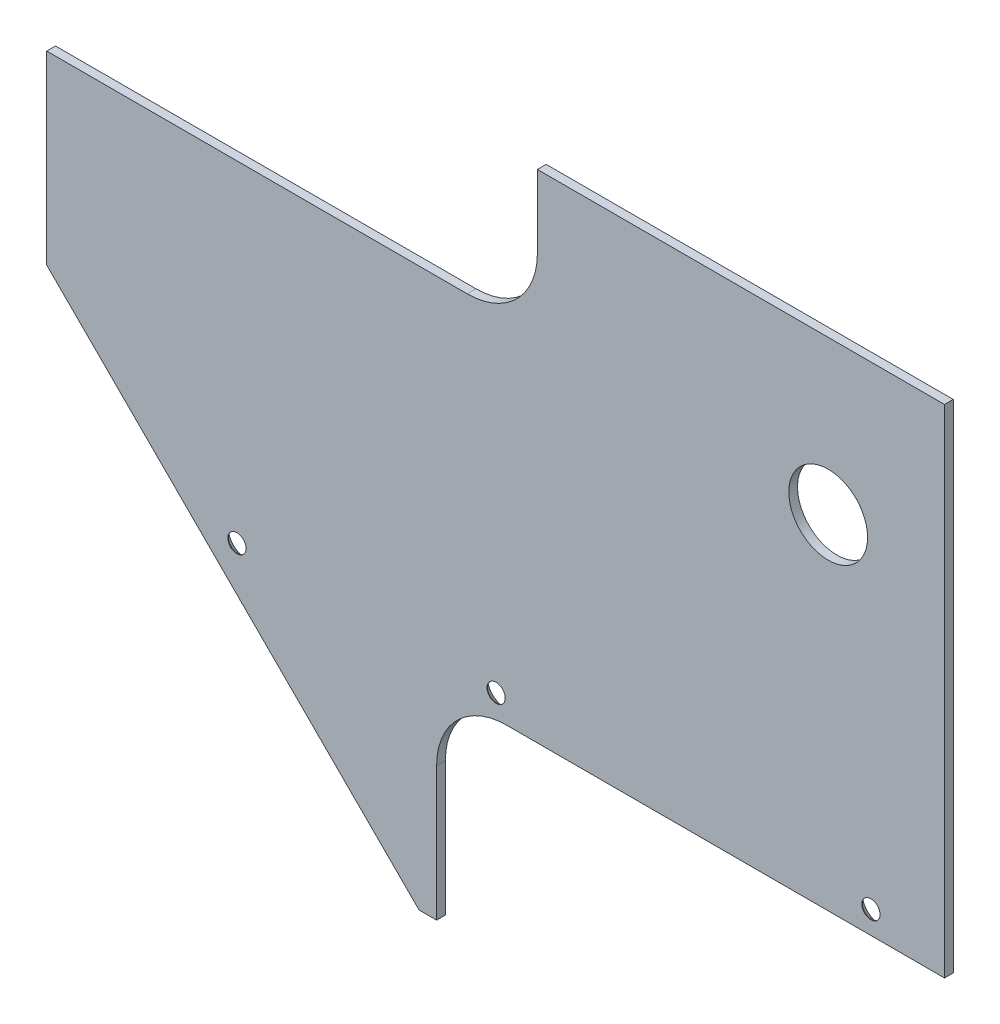
from build123d import *

# Parameters (mm, degrees)
SKETCH1_R                                      = 14.2875
BOSS_EXTRUDE1_DEPTH                            = 3.175
SKETCH2_W                                      = 184.202806358
SKETCH2_H                                      = 73.914
CUT_EXTRUDE1_DEPTH                             = 4.175
FILLET1_R                                      = 25.4
SKETCH4_W                                      = 213.36
SKETCH4_H                                      = 64.479988722
CUT_EXTRUDE2_DEPTH                             = 4.175
FILLET2_R                                      = 25.4
SKETCH7_W                                      = 147.610011278
SKETCH7_H                                      = 12.7
CUT_EXTRUDE4_DEPTH                             = 4.175
CSK_FOR_M6_FLAT_HEAD_MACHINE_SCREW1_AT_2_COUNT = 2
CSK_FOR_M6_FLAT_HEAD_MACHINE_SCREW1_AT_2_PITCH = 135.89
CSK_FOR_M6_FLAT_HEAD_MACHINE_SCREW1_AT_3_COUNT = 2
CSK_FOR_M6_FLAT_HEAD_MACHINE_SCREW1_AT_3_PITCH = 229.87
SKETCH10_W                                     = 57.863879914
SKETCH10_H                                     = 74.228534035
CUT_EXTRUDE5_DEPTH                             = 4.175


with BuildPart() as part:
    # Sketch1 → Boss-Extrude1 (new body)
    with BuildSketch(Plane.XY):
        Polygon((-138.259383474, 48.991487021), (32.210627804, -121.478524257), (222.710627804, -121.478524257), (222.710627804, 145.221475743), (-138.259383474, 145.221475743), align=None)
        with Locations((180.538014078, 76.831975743)):
            Circle(SKETCH1_R, mode=Mode.SUBTRACT)
    extrude(amount=BOSS_EXTRUDE1_DEPTH)

    # Sketch2 → Cut-Extrude1 (cut, through all)
    with BuildSketch(Plane.XY.offset(3.175)):
        with Locations((130.662030983, -84.521524257)):
            Rectangle(SKETCH2_W, SKETCH2_H)
    extrude(amount=-CUT_EXTRUDE1_DEPTH, mode=Mode.SUBTRACT)

    # Fillet1
    fillet1_edges = [part.edges().sort_by_distance(p)[0] for p in [
        (38.560627804, -47.564524257, 1.5875),
    ]]
    fillet(fillet1_edges, radius=FILLET1_R)

    # Sketch4 → Cut-Extrude2 (cut, through all)
    with BuildSketch(Plane.XY.offset(3.175)):
        with Locations((-31.579383474, 112.981481382)):
            Rectangle(SKETCH4_W, SKETCH4_H)
    extrude(amount=-CUT_EXTRUDE2_DEPTH, mode=Mode.SUBTRACT)

    # Fillet2
    fillet2_edges = [part.edges().sort_by_distance(p)[0] for p in [
        (-138.259383474, 80.741487021, 1.5875),
        (75.100616526, 80.741487021, 1.5875),
    ]]
    fillet(fillet2_edges, radius=FILLET2_R)

    # Sketch7 → Cut-Extrude4 (cut, through all)
    with BuildSketch(Plane.XY.offset(3.175)):
        with Locations((148.905622165, 138.871475743)):
            Rectangle(SKETCH7_W, SKETCH7_H)
    extrude(amount=-CUT_EXTRUDE4_DEPTH, mode=Mode.SUBTRACT)

    # Sketch8 → CSK for M6 Flat Head Machine Screw1 (revolve, cut)
    with BuildSketch(Plane(origin=(196.040627804, -39.314524257, 0), x_dir=(0, 1, 0), z_dir=(1, 0, 0))):
        Polygon((0, 0), (0, 3.175), (3.3, 3.175), (3.3, 3), (6.3, 0), align=None)
    csk_for_m6_flat_head_machine_screw1 = revolve(axis=Axis((196.040627804, -39.314524257, -6.35), (0, 0, 1)), mode=Mode.SUBTRACT)

    # CSK for M6 Flat Head Machine Screw1 at 2: CSK for M6 Flat Head Machine Screw1 ×2
    with Locations(*[(-i * CSK_FOR_M6_FLAT_HEAD_MACHINE_SCREW1_AT_2_PITCH, 0, 0) for i in range(1, CSK_FOR_M6_FLAT_HEAD_MACHINE_SCREW1_AT_2_COUNT)]):
        add(csk_for_m6_flat_head_machine_screw1, mode=Mode.SUBTRACT)

    # CSK for M6 Flat Head Machine Screw1 at 3: CSK for M6 Flat Head Machine Screw1 ×2
    with Locations(*[(-i * CSK_FOR_M6_FLAT_HEAD_MACHINE_SCREW1_AT_3_PITCH, 0, 0) for i in range(1, CSK_FOR_M6_FLAT_HEAD_MACHINE_SCREW1_AT_3_COUNT)]):
        add(csk_for_m6_flat_head_machine_screw1, mode=Mode.SUBTRACT)

    # Sketch10 → Cut-Extrude5 (cut, through all)
    with BuildSketch(Plane.XY.offset(3.175)):
        with Locations((-131.722312153, 50.636742761)):
            Rectangle(SKETCH10_W, SKETCH10_H)
    extrude(amount=-CUT_EXTRUDE5_DEPTH, mode=Mode.SUBTRACT)


solid = part.part
